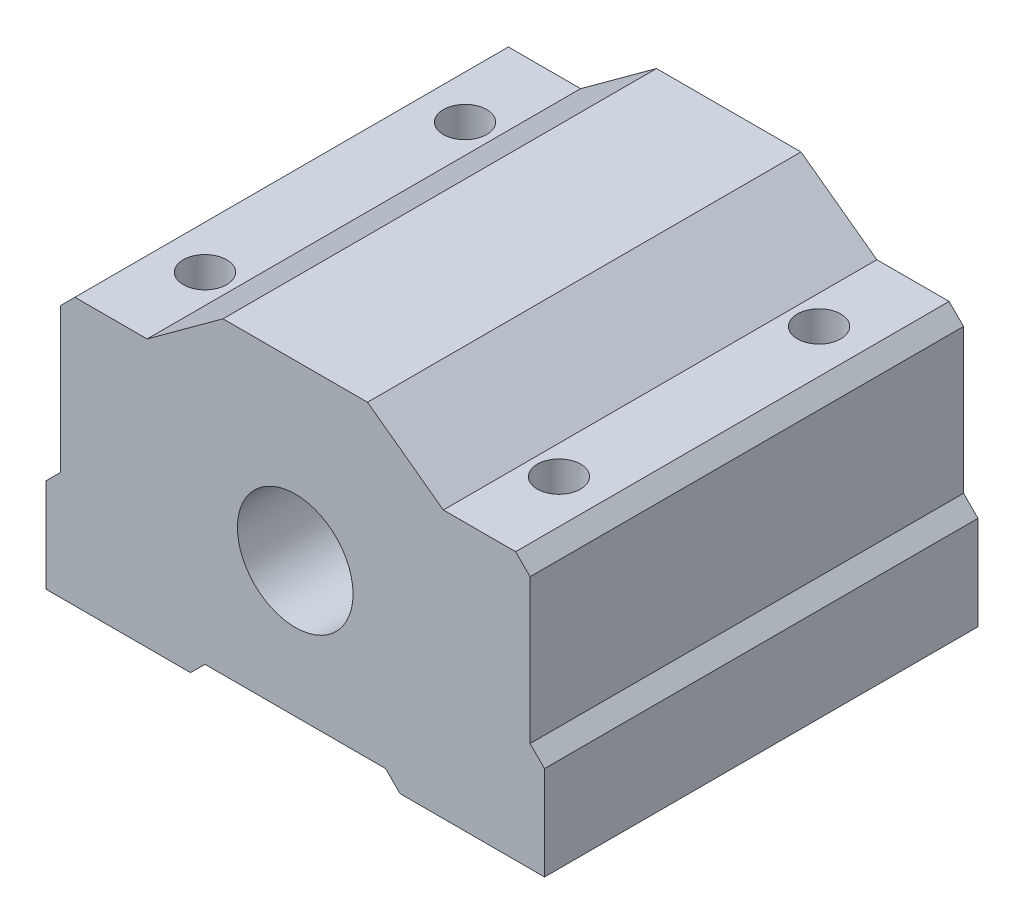
from build123d import *

# Parameters (mm, degrees)
BOSS_EXTRUDE1_DEPTH = 30
SKETCH2_R           = 4
CUT_EXTRUDE1_DEPTH  = 31
SKETCH3_R           = 1.5
CUT_EXTRUDE2_DEPTH  = 19.5


with BuildPart() as part:
    # Sketch1 → Boss-Extrude1 (new body)
    with BuildSketch(Plane.XY):
        Polygon((0, 0), (6.25, 0), (7.25, -1), (17.25, -1), (17.25, 5.5), (16.25, 6.5), (16.25, 16.5), (15.25, 17.5), (10.25, 17.5), (5, 21.332427429), (-5, 21.332427429), (-10.25, 17.5), (-15.25, 17.5), (-16.25, 16.5), (-16.25, 6.5), (-17.25, 5.5), (-17.25, -1), (-7.25, -1), (-6.25, 0), align=None)
    extrude(amount=BOSS_EXTRUDE1_DEPTH)

    # Sketch2 → Cut-Extrude1 (cut, through all)
    with BuildSketch(Plane.XY.offset(30)):
        with Locations((0, 9.332427429)):
            Circle(SKETCH2_R)
    extrude(amount=-CUT_EXTRUDE1_DEPTH, mode=Mode.SUBTRACT)

    # Sketch3 → Cut-Extrude2 (cut, through all)
    with BuildSketch(Plane(origin=(0, 17.5, 0), x_dir=(1, 0, 0), z_dir=(0, 1, 0))):
        with Locations((12.25, -6)):
            Circle(SKETCH3_R)
        with Locations((12.25, -24)):
            Circle(SKETCH3_R)
    cut_extrude2 = extrude(amount=-CUT_EXTRUDE2_DEPTH, mode=Mode.SUBTRACT)

    # Mirror1: Cut-Extrude2 across plane
    add(cut_extrude2.mirror(Plane(origin=(0, 0, 0), x_dir=(0, 0, 1), z_dir=(1, 0, 0))), mode=Mode.SUBTRACT)


solid = part.part
